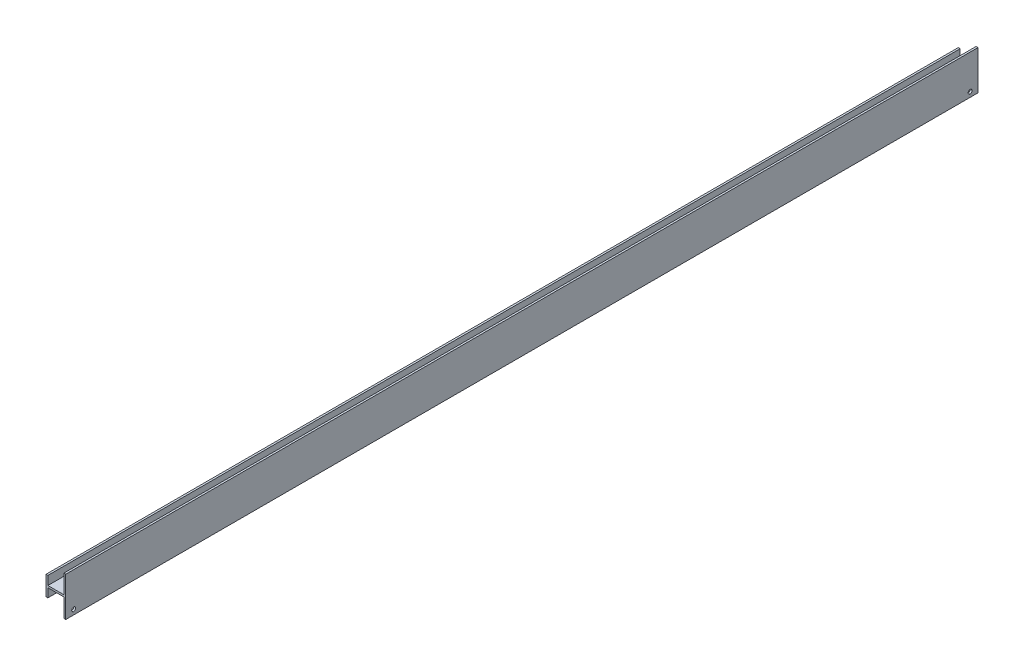
from build123d import *

# Parameters (mm, degrees)
EXTRUDE1_DEPTH     = 364.33125
SKETCH2_R          = 1.5875
CUT_EXTRUDE1_DEPTH = 1.524


with BuildPart() as part:
    # Sketch1 → Extrude1 (new body, symmetric)
    with BuildSketch(Plane.XY):
        Polygon((58.674, 15.6718), (58.674, -15.6718), (57.15, -15.6718), (57.15, -0.762), (44.45, -0.762), (44.45, -7.7851), (42.926, -7.7851), (42.926, 7.7851), (44.45, 7.7851), (44.45, 0.762), (57.15, 0.762), (57.15, 15.6718), align=None)
    extrude(amount=EXTRUDE1_DEPTH, both=True)

    # Sketch2 → Cut-Extrude1 (cut)
    with BuildSketch(Plane.ZY.offset(-57.15)):
        with Locations((357.98125, -11.72845)):
            Circle(SKETCH2_R)
        with Locations((-357.98125, -11.72845)):
            Circle(SKETCH2_R)
    extrude(amount=-CUT_EXTRUDE1_DEPTH, mode=Mode.SUBTRACT)


solid = part.part
